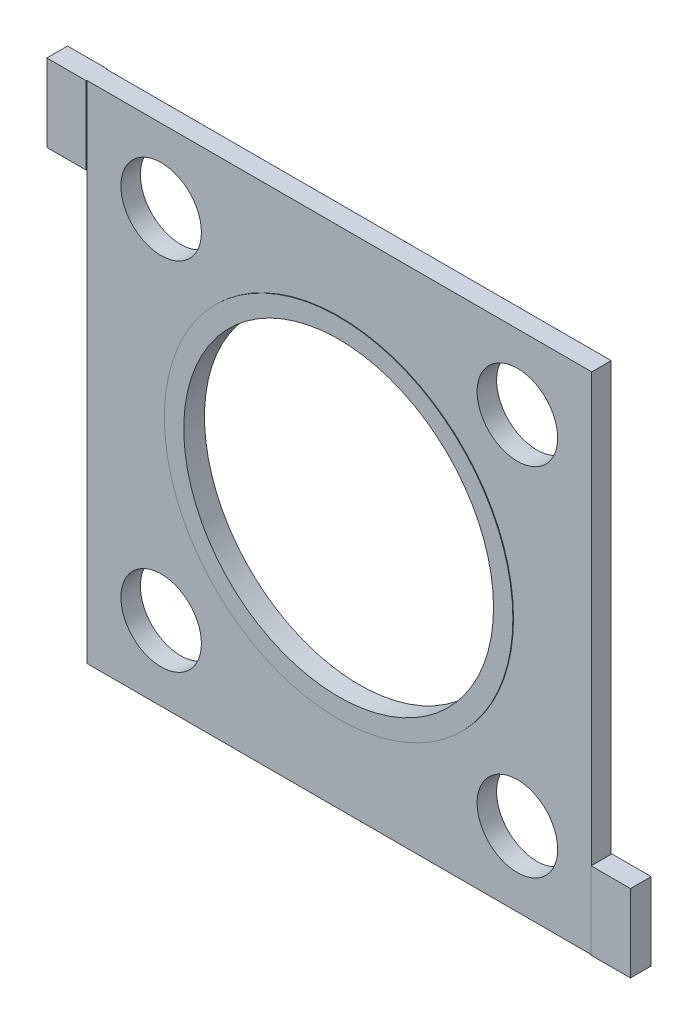
from build123d import *

# Parameters (mm, degrees)
SKETCH1_W                = 41.402
SKETCH1_H                = 41.402
BOSS_EXTRUDE1_DEPTH      = 0.79883
BOSS_EXTRUDE1_DEPTH_BACK = 0.79883
SKETCH2_W                = 3.22834
SKETCH2_H                = 6.35
BOSS_EXTRUDE2_DEPTH      = 0.79883
BOSS_EXTRUDE2_DEPTH_BACK = 0.79883
SKETCH3_R                = 12.7
CUT_EXTRUDE1_DEPTH       = 2.59766
SKETCH4_R                = 14.2875
SKETCH4_R_2              = 12.7
BOSS_EXTRUDE3_DEPTH      = 0.0508
SKETCH5_W                = 3.22834
SKETCH5_H                = 6.35
BOSS_EXTRUDE4_DEPTH      = 0.0508
SKETCH6_R                = 3.302
CUT_EXTRUDE2_DEPTH       = 2.64846


with BuildPart() as part:
    # Sketch1 → Boss-Extrude1 (new body, two sides)
    with BuildSketch(Plane.XY) as boss_extrude1_sk:
        Rectangle(SKETCH1_W, SKETCH1_H)
    extrude(amount=BOSS_EXTRUDE1_DEPTH)
    extrude(boss_extrude1_sk.sketch, amount=-BOSS_EXTRUDE1_DEPTH_BACK)

    # Sketch2 → Boss-Extrude2 (add, two sides)
    with BuildSketch(Plane.XY) as boss_extrude2_sk:
        with Locations((-22.31517, 17.526)):
            Rectangle(SKETCH2_W, SKETCH2_H)
        with Locations((22.31517, -17.526)):
            Rectangle(SKETCH2_W, SKETCH2_H)
    extrude(amount=BOSS_EXTRUDE2_DEPTH)
    extrude(boss_extrude2_sk.sketch, amount=-BOSS_EXTRUDE2_DEPTH_BACK)

    # Sketch3 → Cut-Extrude1 (cut, through all)
    with BuildSketch(Plane.XY.offset(0.79883)):
        Circle(SKETCH3_R)
    extrude(amount=-CUT_EXTRUDE1_DEPTH, mode=Mode.SUBTRACT)

    # Sketch4 → Boss-Extrude3 (add)
    with BuildSketch(Plane.XY.offset(0.79883)):
        Circle(SKETCH4_R)
        Circle(SKETCH4_R_2, mode=Mode.SUBTRACT)
    boss_extrude3 = extrude(amount=BOSS_EXTRUDE3_DEPTH)

    # Sketch5 → Boss-Extrude4 (add)
    with BuildSketch(Plane.XY.offset(0.79883)):
        with Locations((-22.31517, 17.526)):
            Rectangle(SKETCH5_W, SKETCH5_H)
        with Locations((22.31517, -17.526)):
            Rectangle(SKETCH5_W, SKETCH5_H)
    boss_extrude4 = extrude(amount=BOSS_EXTRUDE4_DEPTH)

    # Mirror3: Boss-Extrude3, Boss-Extrude4 across plane
    add(boss_extrude3.mirror(Plane.XY))
    add(boss_extrude4.mirror(Plane.XY))

    # Sketch6 → Cut-Extrude2 (cut, through all)
    with BuildSketch(Plane.XY.offset(0.79883)):
        with Locations((-14.605, 14.605)):
            Circle(SKETCH6_R)
        with Locations((14.605, 14.605)):
            Circle(SKETCH6_R)
    cut_extrude2 = extrude(amount=-CUT_EXTRUDE2_DEPTH, mode=Mode.SUBTRACT)

    # Mirror4: Cut-Extrude2 across plane
    add(cut_extrude2.mirror(Plane.ZX), mode=Mode.SUBTRACT)


solid = part.part
